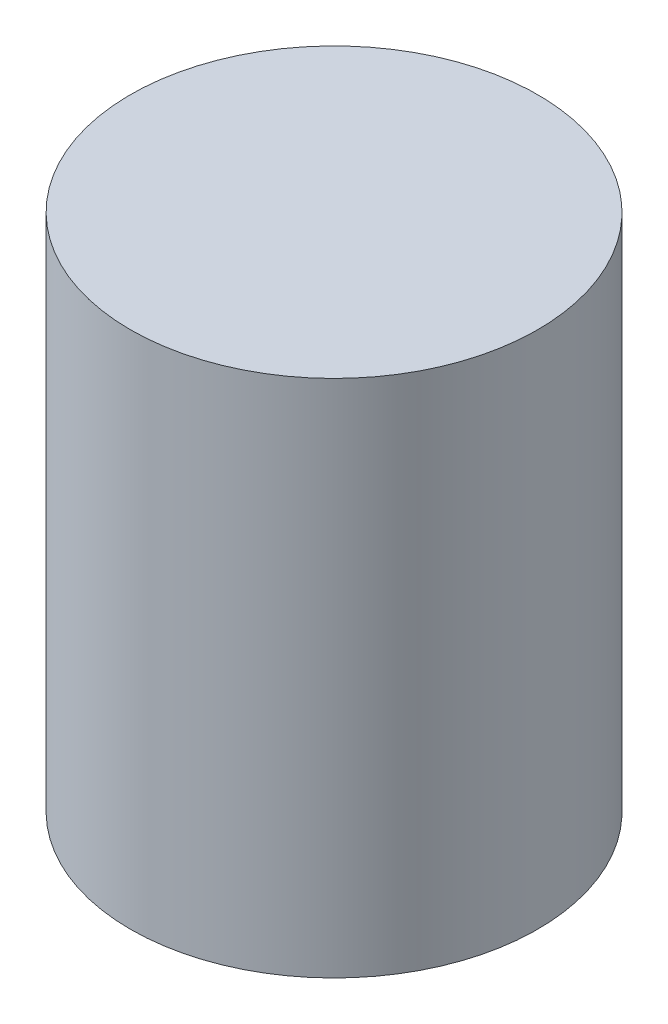
from build123d import *

# Parameters (mm, degrees)
SKETCH1_R           = 11
BOSS_EXTRUDE2_DEPTH = 28.05


with BuildPart() as part:
    # Sketch1 → Boss-Extrude2 (new body)
    with BuildSketch(Plane(origin=(0, 0, 0), x_dir=(1, 0, 0), z_dir=(0, 1, 0))):
        with Locations((-22.770576779, 24.323116105)):
            Circle(SKETCH1_R)
    extrude(amount=BOSS_EXTRUDE2_DEPTH)


solid = part.part
